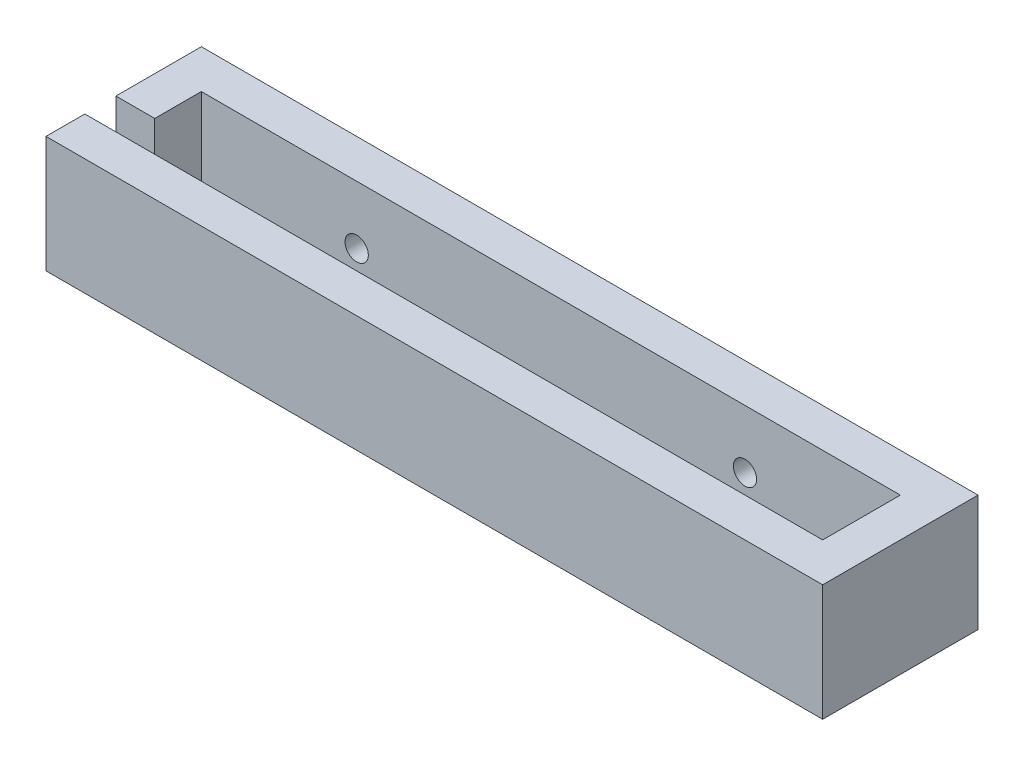
from build123d import *

# Parameters (mm, degrees)
SKETCH_2_W          = 100
SKETCH_2_H          = 20
EXTRUDE_1_DEPTH     = 15
SKETCH_3_W          = 90
SKETCH_3_H          = 10
CUT_EXTRUDE_1_DEPTH = 10
SKETCH_5_W          = 5
SKETCH_5_H          = 4
CUT_EXTRUDE_2_DEPTH = 10
CUT_EXTRUDE_3_REACH = 22
SKETCH_6_R          = 1.5


with BuildPart() as part:
    # 草图2 → 凸台-拉伸1 (new body)
    with BuildSketch(Plane(origin=(0, 0, 0), x_dir=(1, 0, 0), z_dir=(0, 1, 0))):
        with Locations((26.720720721, -4.31981982)):
            Rectangle(SKETCH_2_W, SKETCH_2_H)
    extrude(amount=EXTRUDE_1_DEPTH)

    # 草图3 → 切除-拉伸1 (cut)
    with BuildSketch(Plane(origin=(0, 15, 0), x_dir=(1, 0, 0), z_dir=(0, 1, 0))):
        with Locations((26.720720721, -4.31981982)):
            Rectangle(SKETCH_3_W, SKETCH_3_H)
    extrude(amount=-CUT_EXTRUDE_1_DEPTH, mode=Mode.SUBTRACT)

    # 草图5 → 切除-拉伸2 (cut)
    with BuildSketch(Plane(origin=(0, 15, 0), x_dir=(1, 0, 0), z_dir=(0, 1, 0))):
        with Locations((-20.779279279, -7.31981982)):
            Rectangle(SKETCH_5_W, SKETCH_5_H)
    extrude(amount=-CUT_EXTRUDE_2_DEPTH, mode=Mode.SUBTRACT)

    # 草图6 → 切除-拉伸3 (cut, up to next)
    with BuildSketch(Plane(origin=(0, 0, -5.68018018), x_dir=(-1, 0, 0), z_dir=(0, 0, -1)), mode=Mode.PRIVATE) as cut_extrude_3_sk1:
        with Locations((-1.720720721, 7.5)):
            Circle(SKETCH_6_R)
    cut_extrude_3_tool1 = extrude(cut_extrude_3_sk1.sketch, amount=-CUT_EXTRUDE_3_REACH, mode=Mode.PRIVATE) & part.part
    add(cut_extrude_3_tool1.solids().sort_by_distance((1.720721, 7.5, -5.68018))[0], mode=Mode.SUBTRACT)
    # 草图6 → 切除-拉伸3 (cut, up to next)
    with BuildSketch(Plane(origin=(0, 0, -5.68018018), x_dir=(-1, 0, 0), z_dir=(0, 0, -1)), mode=Mode.PRIVATE) as cut_extrude_3_sk2:
        with Locations((-51.720720721, 7.5)):
            Circle(SKETCH_6_R)
    cut_extrude_3_tool2 = extrude(cut_extrude_3_sk2.sketch, amount=-CUT_EXTRUDE_3_REACH, mode=Mode.PRIVATE) & part.part
    add(cut_extrude_3_tool2.solids().sort_by_distance((51.720721, 7.5, -5.68018))[0], mode=Mode.SUBTRACT)


solid = part.part
